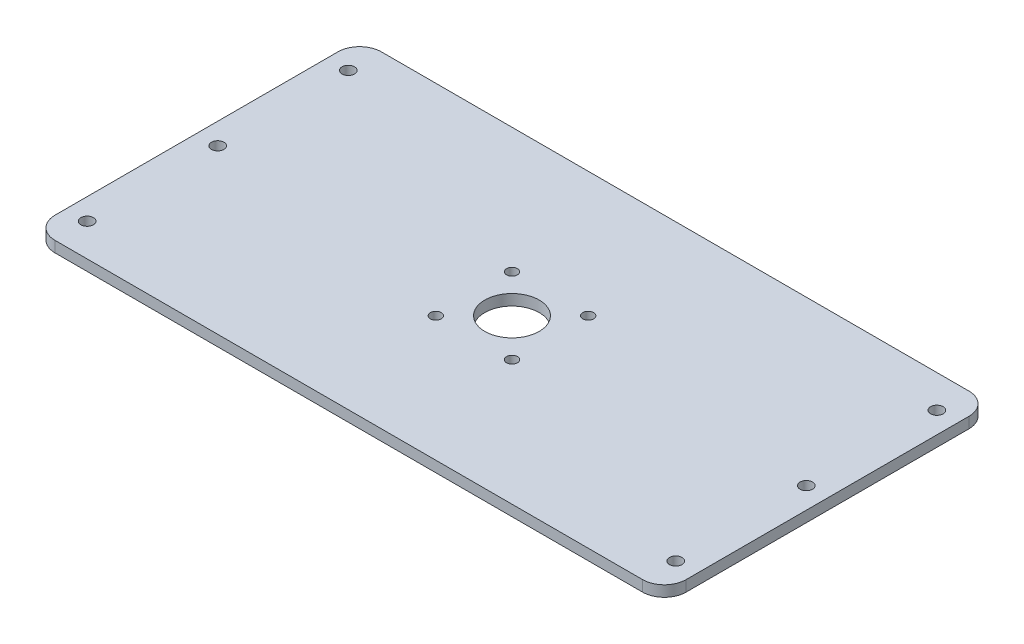
from build123d import *

# Parameters (mm, degrees)
SKETCH1_W           = 290
SKETCH1_H           = 150
SKETCH1_R           = 2.875
SKETCH1_R_2         = 12.5
SKETCH1_R_3         = 2.5
BOSS_EXTRUDE2_DEPTH = 5
FILLET1_R           = 10


with BuildPart() as part:
    # Sketch1 → Boss-Extrude2 (new body)
    with BuildSketch(Plane(origin=(0, 0, 0), x_dir=(1, 0, 0), z_dir=(0, 1, 0))):
        Rectangle(SKETCH1_W, SKETCH1_H)
        with Locations((-135.225, 0)):
            Circle(SKETCH1_R, mode=Mode.SUBTRACT)
        with Locations((135.225, 0)):
            Circle(SKETCH1_R, mode=Mode.SUBTRACT)
        with Locations((135.225, 60)):
            Circle(SKETCH1_R, mode=Mode.SUBTRACT)
        with Locations((-135.225, 60)):
            Circle(SKETCH1_R, mode=Mode.SUBTRACT)
        with Locations((-135.225, -60)):
            Circle(SKETCH1_R, mode=Mode.SUBTRACT)
        with Locations((135.225, -60)):
            Circle(SKETCH1_R, mode=Mode.SUBTRACT)
        Circle(SKETCH1_R_2, mode=Mode.SUBTRACT)
        with Locations((-17.5, 17.5)):
            Circle(SKETCH1_R_3, mode=Mode.SUBTRACT)
        with Locations((17.5, 17.5)):
            Circle(SKETCH1_R_3, mode=Mode.SUBTRACT)
        with Locations((17.5, -17.5)):
            Circle(SKETCH1_R_3, mode=Mode.SUBTRACT)
        with Locations((-17.5, -17.5)):
            Circle(SKETCH1_R_3, mode=Mode.SUBTRACT)
    extrude(amount=BOSS_EXTRUDE2_DEPTH)

    # Fillet1
    fillet1_edges = [part.edges().sort_by_distance(p)[0] for p in [
        (-145, 2.5, -75),
        (145, 2.5, -75),
        (145, 2.5, 75),
        (-145, 2.5, 75),
    ]]
    fillet(fillet1_edges, radius=FILLET1_R)


solid = part.part
